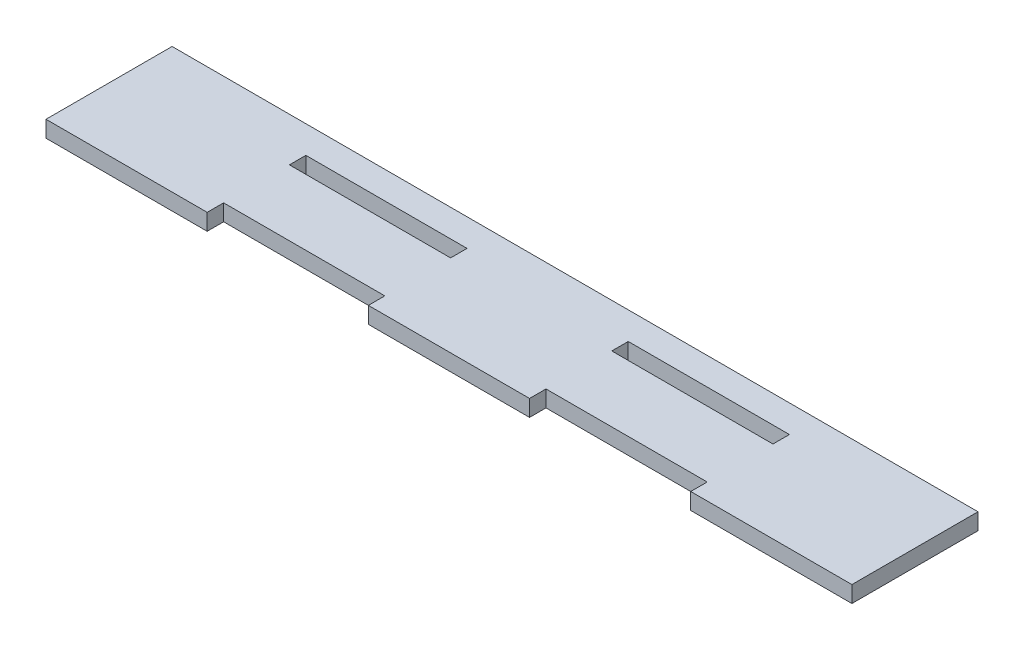
from build123d import *

# Parameters (mm, degrees)
SKETCH1_W           = 29.4
SKETCH1_H           = 3
BOSS_EXTRUDE1_DEPTH = 3


with BuildPart() as part:
    # Sketch1 → Boss-Extrude1 (new body)
    with BuildSketch(Plane(origin=(0, 0, 0), x_dir=(1, 0, 0), z_dir=(0, 1, 0))):
        Polygon((-73.5, 7.5), (73.5, 7.5), (73.5, -15.5), (44.1, -15.5), (44.1, -12.5), (14.7, -12.5), (14.7, -15.5), (-14.7, -15.5), (-14.7, -12.5), (-44.1, -12.5), (-44.1, -15.5), (-73.5, -15.5), align=None)
        with Locations((29.4, 1)):
            Rectangle(SKETCH1_W, SKETCH1_H, mode=Mode.SUBTRACT)
        with Locations((-29.4, 1)):
            Rectangle(SKETCH1_W, SKETCH1_H, mode=Mode.SUBTRACT)
    extrude(amount=BOSS_EXTRUDE1_DEPTH)


solid = part.part
